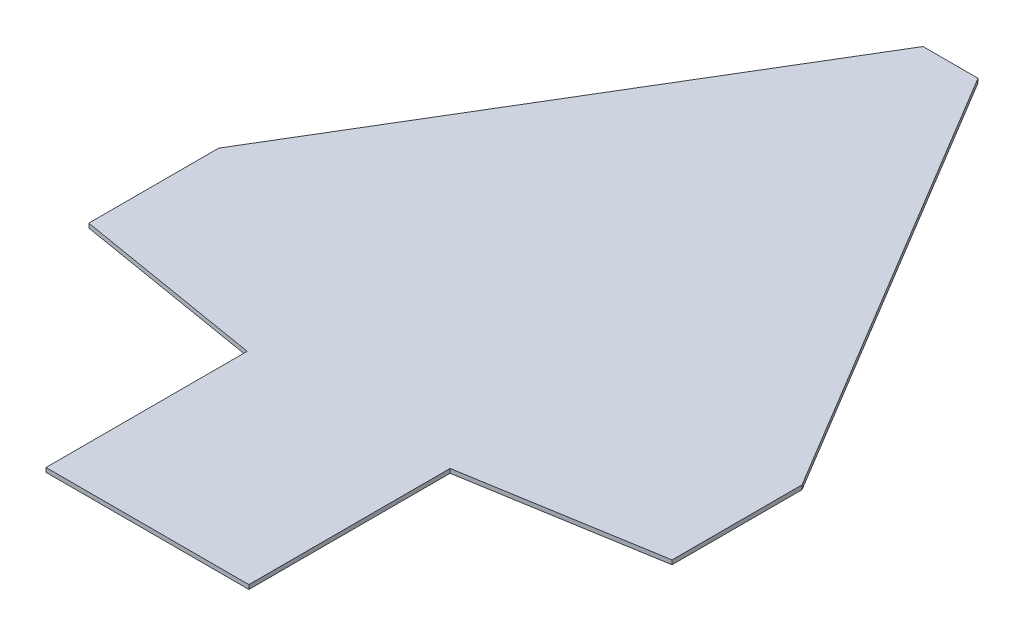
from build123d import *

# Parameters (mm, degrees)
BOSS_EXTRUDE1_DEPTH = 2.54


with BuildPart() as part:
    # Sketch1 → Boss-Extrude1 (new body)
    with BuildSketch(Plane(origin=(0, 0, 0), x_dir=(1, 0, 0), z_dir=(0, 1, 0))):
        Polygon((39.942504941, 82.213636442), (6.891436034, 82.213636442), (-151.843029513, -182.285067863), (-151.843029513, -260.380136683), (-37.543029513, -279.472432378), (-37.543029513, -400.386363558), (84.376970487, -400.386363558), (84.376970487, -279.472432378), (198.676970487, -260.380136683), (198.676970487, -182.285067863), align=None)
    extrude(amount=BOSS_EXTRUDE1_DEPTH)


solid = part.part
